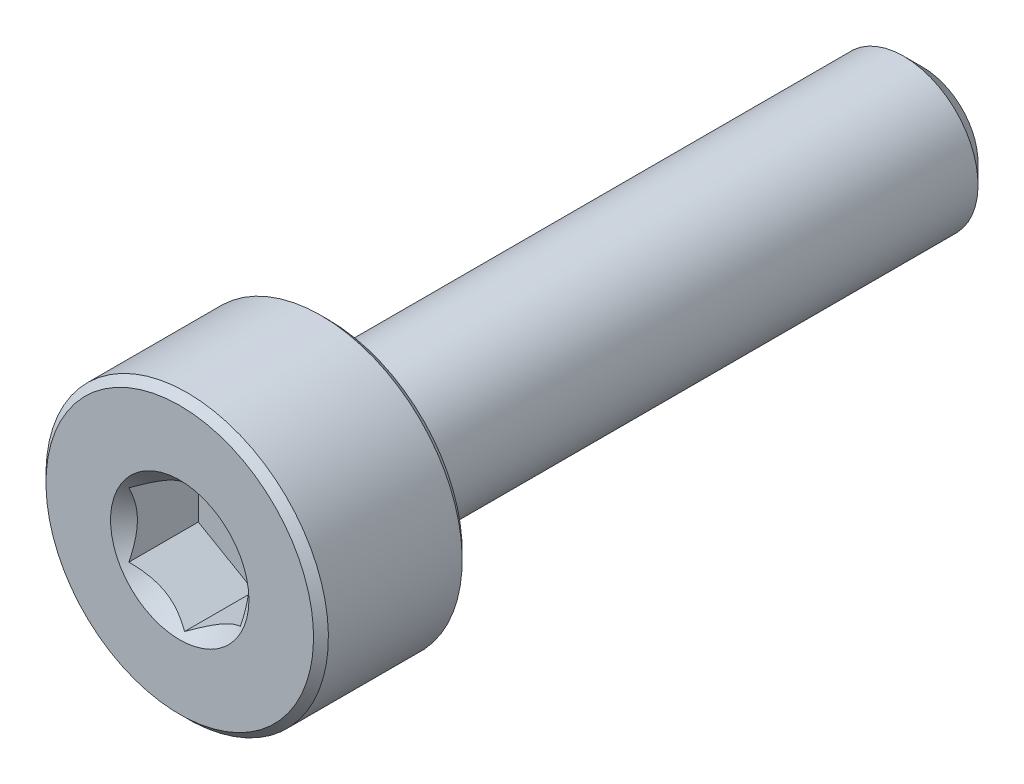
from build123d import *

# Parameters (mm, degrees)
CUT_EXTRUDE1_DEPTH = 1
SKETCH4_R          = 0.930977309
CUT_EXTRUDE2_DEPTH = 1
CUT_EXTRUDE2_DRAFT = -45


with BuildPart() as part:
    # Sketch2 → Revolve1 (revolve)
    with BuildSketch(Plane(origin=(0, 0, 0), x_dir=(0, 0, -1), z_dir=(1, 0, 0))):
        with BuildLine():
            Line((-5, 0), (-5, 1.8))
            Line((-5, 1.8), (-4.9, 1.9))
            Line((-4.9, 1.9), (-3.1, 1.9))
            Line((-3.1, 1.9), (-3, 1.8))
            Line((-3, 1.8), (-3, 1.1))
            ThreePointArc((-3, 1.1), (-2.970710678, 1.029289322), (-2.9, 1))
            Line((-2.9, 1), (4.740192379, 1))
            Line((4.740192379, 1), (5, 0.740192379))
            Line((5, 0.740192379), (5, 0))
            Line((5, 0), (-5, 0))
        make_face()
    revolve(axis=Axis((0, 0, -5), (0, 0, 1)))

    # Sketch3 → Cut-Extrude1 (cut)
    with BuildSketch(Plane.XY.offset(5)):
        Polygon((0.75, -0.433012702), (0.75, 0.433012702), (0, 0.866025404), (-0.75, 0.433012702), (-0.75, -0.433012702), (0, -0.866025404), align=None)
    extrude(amount=-CUT_EXTRUDE1_DEPTH, mode=Mode.SUBTRACT)


with BuildPart() as cut_extrude2_tool:
    # Sketch4 → Cut-Extrude2 (with draft: the straight prism first)
    with BuildSketch(Plane.XY.offset(5)):
        Circle(SKETCH4_R)
    extrude(amount=-CUT_EXTRUDE2_DEPTH)
    # Cut-Extrude2: the draft: its side faces are tilted about the plane it starts from
    cut_extrude2_sides = [cut_extrude2_tool.faces().sort_by_distance(p)[0] for p in [
        (-0.930977309, 0, 4.5),
    ]]
    draft(cut_extrude2_sides, Plane.XY.offset(5), CUT_EXTRUDE2_DRAFT)


with BuildPart() as part_1:
    add(part.part)

    # Cut-Extrude2: cut by cut_extrude2_tool
    add(cut_extrude2_tool.part, mode=Mode.SUBTRACT)


solid = part_1.part
